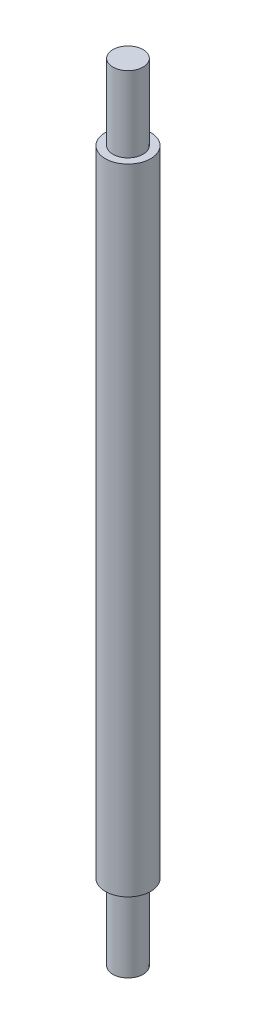
from build123d import *


with BuildPart() as part:
    # Sketch1 → Revolve1 (revolve)
    with BuildSketch(Plane.XY):
        Polygon((0, 0), (2, 0), (2, 10), (3, 10), (3, 94), (2, 94), (2, 104), (0, 104), align=None)
    revolve(axis=Axis((0, 104, 0), (0, -1, 0)))


solid = part.part
